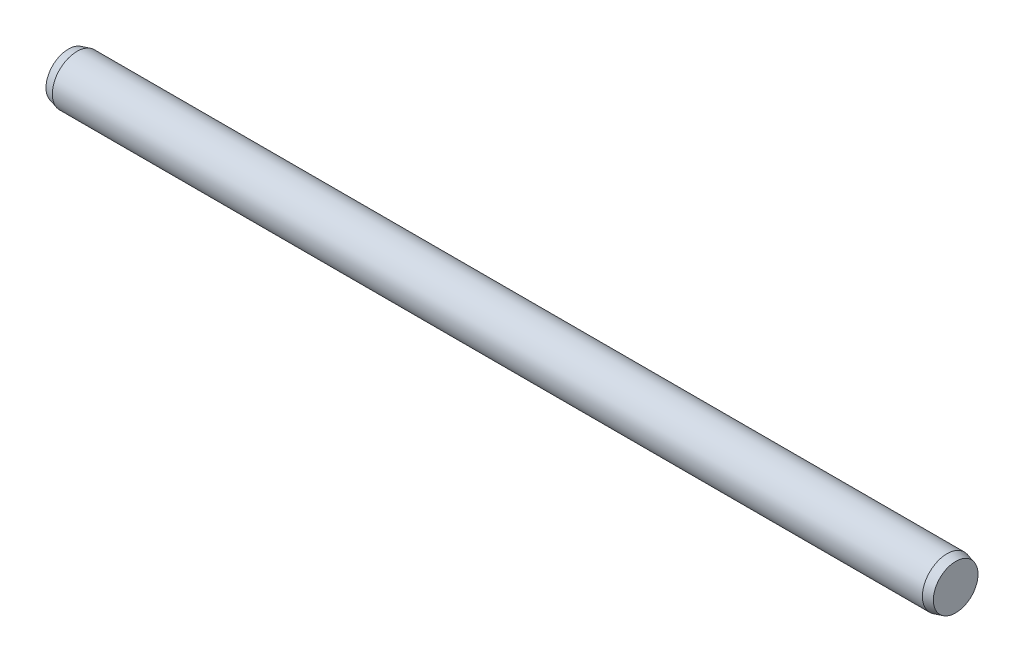
from build123d import *

# Parameters (mm, degrees)
SKETCH2_R           = 1
EXTRUDE1_DEPTH      = 17.65
EXTRUDE1_DEPTH_BACK = 17.65
SKETCH3_R           = 1
EXTRUDE2_DEPTH      = 0.35
EXTRUDE2_TAPER      = 15
SKETCH4_R           = 1
EXTRUDE3_DEPTH      = 0.35
EXTRUDE3_TAPER      = 15


with BuildPart() as part:
    # Sketch2 → Extrude1 (new body, two sides)
    with BuildSketch(Plane(origin=(0, 0, 0), x_dir=(0, 0, -1), z_dir=(1, 0, 0))) as extrude1_sk:
        Circle(SKETCH2_R)
    extrude(amount=EXTRUDE1_DEPTH)
    extrude(extrude1_sk.sketch, amount=-EXTRUDE1_DEPTH_BACK)

    # Sketch3 → Extrude2 (add)
    with BuildSketch(Plane(origin=(17.65, 0, 0), x_dir=(0, 0, -1), z_dir=(1, 0, 0))):
        Circle(SKETCH3_R)
    extrude(amount=EXTRUDE2_DEPTH, taper=EXTRUDE2_TAPER)

    # Sketch4 → Extrude3 (add)
    with BuildSketch(Plane.ZY.offset(17.65)):
        Circle(SKETCH4_R)
    extrude(amount=EXTRUDE3_DEPTH, taper=EXTRUDE3_TAPER)


solid = part.part
